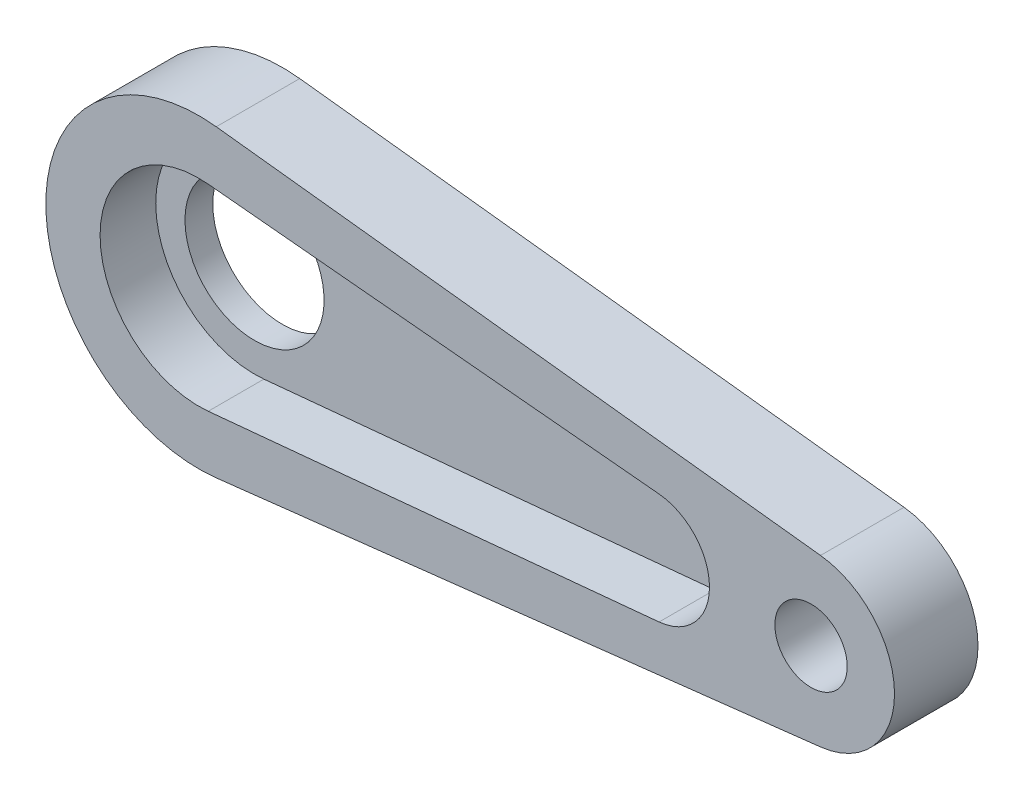
from build123d import *
from build123d.topology import SkipClean

# Parameters (mm, degrees)
MAIN_DEPTH            = 2
ESQUISSE2_R           = 2.5
ORIGINALBRACKET_DEPTH = 1
ESQUISSE3_R           = 1.3
FIXINGHOLE_DEPTH      = 26.773047938


with BuildPart() as part:
    # Esquisse1 → Main (new body)
    with BuildSketch(Plane.XY):
        with BuildLine():
            Line((0.625, 5.464373249), (22.340909091, 2.980567227))
            ThreePointArc((22.340909091, 2.980567227), (25, 0), (22.340909091, -2.980567227))
            Line((22.340909091, -2.980567227), (0.625, -5.464373249))
            ThreePointArc((0.625, -5.464373249), (-5.5, 0), (0.625, 5.464373249))
        make_face()
        with BuildLine():
            Line((0.336544343, 3.534011588), (16.539602446, 1.990992444))
            ThreePointArc((16.539602446, 1.990992444), (18.35, 0), (16.539602446, -1.990992444))
            Line((16.539602446, -1.990992444), (0.336544343, -3.534011588))
            ThreePointArc((0.336544343, -3.534011588), (-3.55, 0), (0.336544343, 3.534011588))
        make_face(mode=Mode.SUBTRACT)
    extrude(amount=MAIN_DEPTH)

    # Esquisse2 → OriginalBracket (add)
    with SkipClean():  # the faces are left unmerged after this step: merging them gives an invalid solid
        with BuildSketch(Plane(origin=(0, 0, 0), x_dir=(-1, 0, 0), z_dir=(0, 0, -1))):
            with BuildLine():
                Line((-0.625, -5.464373249), (-22.340909091, -2.980567227))
                ThreePointArc((-22.340909091, -2.980567227), (-25, 0), (-22.340909091, 2.980567227))
                Line((-22.340909091, 2.980567227), (-0.625, 5.464373249))
                ThreePointArc((-0.625, 5.464373249), (5.5, 0), (-0.625, -5.464373249))
            make_face()
            Circle(ESQUISSE2_R, mode=Mode.SUBTRACT)
        extrude(amount=ORIGINALBRACKET_DEPTH)

    # Esquisse3 → FixingHole (cut, through all)
    with SkipClean():  # the faces are left unmerged after this step: merging them gives an invalid solid
        with BuildSketch(Plane.XY.offset(2)):
            with Locations((22, 0)):
                Circle(ESQUISSE3_R)
        extrude(amount=-FIXINGHOLE_DEPTH, mode=Mode.SUBTRACT)


solid = part.part
